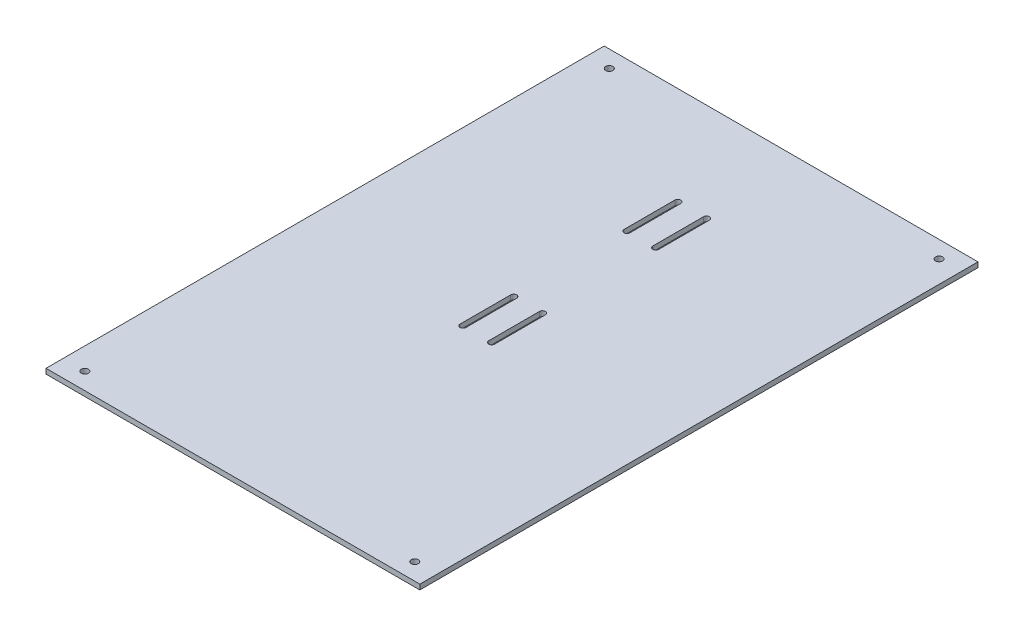
from build123d import *

# Parameters (mm, degrees)
SKETCH1_W                = 330
SKETCH1_H                = 3
EXTRUDE_THIN1_DEPTH      = 110.5
EXTRUDE_THIN1_DEPTH_BACK = 110.5
CUT_EXTRUDE1_REACH       = 5
SKETCH2_R                = 2.1


with BuildPart() as part:
    # Sketch1 → Extrude-Thin1 (new body, two sides)
    with BuildSketch(Plane(origin=(0, 0, 0), x_dir=(0, 0, -1), z_dir=(1, 0, 0))) as extrude_thin1_sk:
        with Locations((-42.5, -11.5)):
            Rectangle(SKETCH1_W, SKETCH1_H)
    extrude(amount=EXTRUDE_THIN1_DEPTH)
    extrude(extrude_thin1_sk.sketch, amount=-EXTRUDE_THIN1_DEPTH_BACK)

    # Sketch2 → Cut-Extrude1 (cut, up to next)
    with BuildSketch(Plane.XZ.offset(13), mode=Mode.PRIVATE) as cut_extrude1_sk1:
        with Locations((97.5, -112.5)):
            Circle(SKETCH2_R)
    cut_extrude1_tool1 = extrude(cut_extrude1_sk1.sketch, amount=-CUT_EXTRUDE1_REACH, mode=Mode.PRIVATE) & part.part
    add(cut_extrude1_tool1.solids().sort_by_distance((97.5, -13, -112.5))[0], mode=Mode.SUBTRACT)
    # Sketch2 → Cut-Extrude1 (cut, up to next)
    with BuildSketch(Plane.XZ.offset(13), mode=Mode.PRIVATE) as cut_extrude1_sk2:
        with Locations((-97.5, -112.5)):
            Circle(SKETCH2_R)
    cut_extrude1_tool2 = extrude(cut_extrude1_sk2.sketch, amount=-CUT_EXTRUDE1_REACH, mode=Mode.PRIVATE) & part.part
    add(cut_extrude1_tool2.solids().sort_by_distance((-97.5, -13, -112.5))[0], mode=Mode.SUBTRACT)
    # Sketch2 → Cut-Extrude1 (cut, up to next)
    with BuildSketch(Plane.XZ.offset(13), mode=Mode.PRIVATE) as cut_extrude1_sk3:
        with Locations((97.5, 197.5)):
            Circle(SKETCH2_R)
    cut_extrude1_tool3 = extrude(cut_extrude1_sk3.sketch, amount=-CUT_EXTRUDE1_REACH, mode=Mode.PRIVATE) & part.part
    add(cut_extrude1_tool3.solids().sort_by_distance((97.5, -13, 197.5))[0], mode=Mode.SUBTRACT)
    # Sketch2 → Cut-Extrude1 (cut, up to next)
    with BuildSketch(Plane.XZ.offset(13), mode=Mode.PRIVATE) as cut_extrude1_sk4:
        with Locations((-97.5, 197.5)):
            Circle(SKETCH2_R)
    cut_extrude1_tool4 = extrude(cut_extrude1_sk4.sketch, amount=-CUT_EXTRUDE1_REACH, mode=Mode.PRIVATE) & part.part
    add(cut_extrude1_tool4.solids().sort_by_distance((-97.5, -13, 197.5))[0], mode=Mode.SUBTRACT)
    # Sketch2 → Cut-Extrude1 (cut, up to next)
    with BuildSketch(Plane.XZ.offset(13), mode=Mode.PRIVATE) as cut_extrude1_sk5:
        with BuildLine():
            Line((-7.243170513, -34.5), (-7.243170513, -64.5))
            ThreePointArc((-7.243170513, -64.5), (-8.993170513, -66.25), (-10.743170513, -64.5))
            Line((-10.743170513, -64.5), (-10.743170513, -34.5))
            ThreePointArc((-10.743170513, -34.5), (-8.993170513, -32.75), (-7.243170513, -34.5))
        make_face()
    cut_extrude1_tool5 = extrude(cut_extrude1_sk5.sketch, amount=-CUT_EXTRUDE1_REACH, mode=Mode.PRIVATE) & part.part
    add(cut_extrude1_tool5.solids().sort_by_distance((-8.993171, -13, -49.5))[0], mode=Mode.SUBTRACT)
    # Sketch2 → Cut-Extrude1 (cut, up to next)
    with BuildSketch(Plane.XZ.offset(13), mode=Mode.PRIVATE) as cut_extrude1_sk6:
        with BuildLine():
            Line((9.756829487, -34.5), (9.756829487, -64.5))
            ThreePointArc((9.756829487, -64.5), (8.006829487, -66.25), (6.256829487, -64.5))
            Line((6.256829487, -64.5), (6.256829487, -34.5))
            ThreePointArc((6.256829487, -34.5), (8.006829487, -32.75), (9.756829487, -34.5))
        make_face()
    cut_extrude1_tool6 = extrude(cut_extrude1_sk6.sketch, amount=-CUT_EXTRUDE1_REACH, mode=Mode.PRIVATE) & part.part
    add(cut_extrude1_tool6.solids().sort_by_distance((8.006829, -13, -49.5))[0], mode=Mode.SUBTRACT)
    # Sketch2 → Cut-Extrude1 (cut, up to next)
    with BuildSketch(Plane.XZ.offset(13), mode=Mode.PRIVATE) as cut_extrude1_sk7:
        with BuildLine():
            Line((9.756829487, 62.5), (9.756829487, 32.5))
            ThreePointArc((9.756829487, 32.5), (8.006829487, 30.75), (6.256829487, 32.5))
            Line((6.256829487, 32.5), (6.256829487, 62.5))
            ThreePointArc((6.256829487, 62.5), (8.006829487, 64.25), (9.756829487, 62.5))
        make_face()
    cut_extrude1_tool7 = extrude(cut_extrude1_sk7.sketch, amount=-CUT_EXTRUDE1_REACH, mode=Mode.PRIVATE) & part.part
    add(cut_extrude1_tool7.solids().sort_by_distance((8.006829, -13, 47.5))[0], mode=Mode.SUBTRACT)
    # Sketch2 → Cut-Extrude1 (cut, up to next)
    with BuildSketch(Plane.XZ.offset(13), mode=Mode.PRIVATE) as cut_extrude1_sk8:
        with BuildLine():
            Line((-7.243170513, 62.5), (-7.243170513, 32.5))
            ThreePointArc((-7.243170513, 32.5), (-8.993170513, 30.75), (-10.743170513, 32.5))
            Line((-10.743170513, 32.5), (-10.743170513, 62.5))
            ThreePointArc((-10.743170513, 62.5), (-8.993170513, 64.25), (-7.243170513, 62.5))
        make_face()
    cut_extrude1_tool8 = extrude(cut_extrude1_sk8.sketch, amount=-CUT_EXTRUDE1_REACH, mode=Mode.PRIVATE) & part.part
    add(cut_extrude1_tool8.solids().sort_by_distance((-8.993171, -13, 47.5))[0], mode=Mode.SUBTRACT)


solid = part.part
